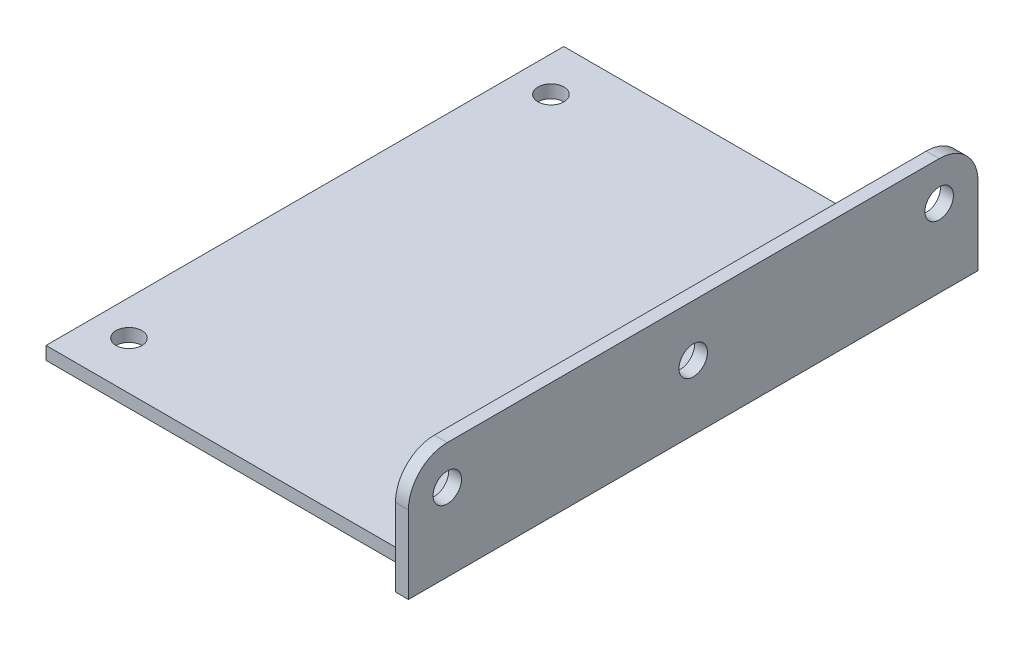
from build123d import *

# Parameters (mm, degrees)
SKETCH1_W                 = 30
SKETCH1_H                 = 40
BOSS_EXTRUDE1_DEPTH       = 1
SKETCH4_W                 = 1
SKETCH4_H                 = 44
BOSS_EXTRUDE2_DEPTH       = 9
SKETCH5_R                 = 1.1
CUT_EXTRUDE1_DEPTH        = 1
F_2_0MM_DOWEL_HOLE1_D     = 2
F_2_0MM_DOWEL_HOLE1_DEPTH = 2.6
F_2_0MM_DOWEL_HOLE1_TIP   = 0.600860619
FILLET3_R                 = 3


with BuildPart() as part:
    # Sketch1 → Boss-Extrude1 (new body)
    with BuildSketch(Plane(origin=(0, 0, 0), x_dir=(1, 0, 0), z_dir=(0, 1, 0))):
        with Locations((-15, 0)):
            Rectangle(SKETCH1_W, SKETCH1_H)
    extrude(amount=BOSS_EXTRUDE1_DEPTH)

    # Sketch4 → Boss-Extrude2 (add)
    with BuildSketch(Plane(origin=(0, 0, 0), x_dir=(1, 0, 0), z_dir=(0, 1, 0))):
        with Locations((-0.5, 0)):
            Rectangle(SKETCH4_W, SKETCH4_H)
    extrude(amount=BOSS_EXTRUDE2_DEPTH)

    # Sketch5 → Cut-Extrude1 (cut)
    with BuildSketch(Plane(origin=(0, 0, 0), x_dir=(0, 0, -1), z_dir=(1, 0, 0))):
        with Locations((-19, 6)):
            Circle(SKETCH5_R)
        with Locations((19, 6)):
            Circle(SKETCH5_R)
        with Locations((0, 5)):
            Circle(SKETCH5_R)
    extrude(amount=-CUT_EXTRUDE1_DEPTH, mode=Mode.SUBTRACT)

    # Ø2.0mm Dowel Hole1
    with Locations(Plane(origin=(0, 0, 0), x_dir=(-1, 0, 0), z_dir=(0, -1, 0))):
        with Locations((27.29, -16.3), (27.29, 16.3)):
            Hole(F_2_0MM_DOWEL_HOLE1_D / 2, depth=F_2_0MM_DOWEL_HOLE1_DEPTH)
            with Locations((0, 0, -(F_2_0MM_DOWEL_HOLE1_DEPTH + F_2_0MM_DOWEL_HOLE1_TIP / 2))):  # 118° drill point
                Cone(0, F_2_0MM_DOWEL_HOLE1_D / 2, F_2_0MM_DOWEL_HOLE1_TIP, mode=Mode.SUBTRACT)

    # Fillet3
    fillet3_edges = [part.edges().sort_by_distance(p)[0] for p in [
        (-0.5, 9, -22),
        (-0.5, 9, 22),
    ]]
    fillet(fillet3_edges, radius=FILLET3_R)


solid = part.part
